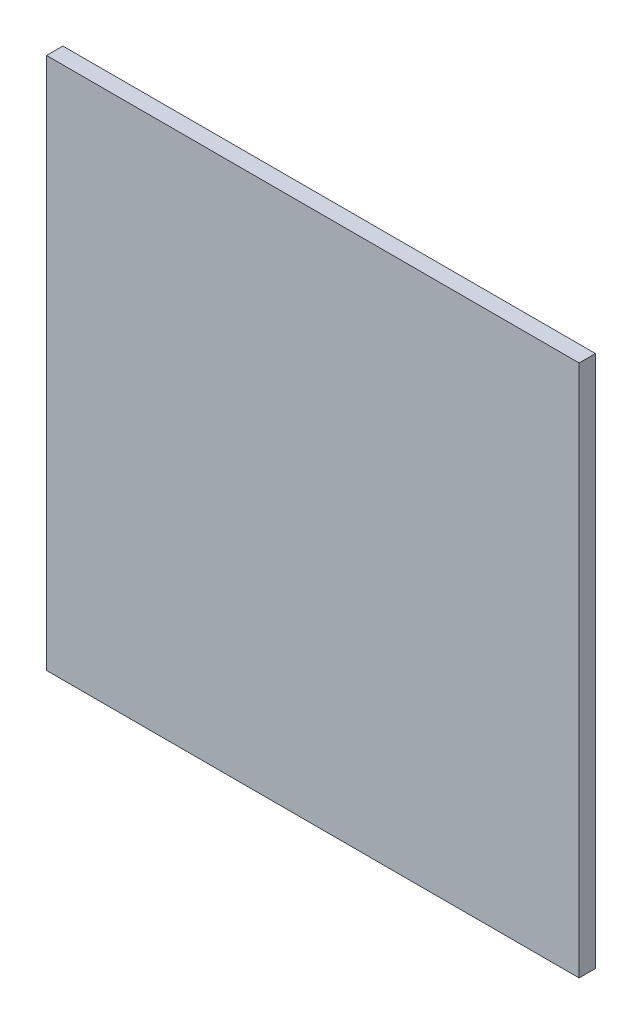
from build123d import *

# Parameters (mm, degrees)
SKETCH_1_W      = 75
SKETCH_1_H      = 75
EXTRUDE_1_DEPTH = 2.3


with BuildPart() as part:
    # 草图1 → 凸台-拉伸1 (new body)
    with BuildSketch(Plane.XY):
        with Locations((303.743807328, 184.689725504)):
            Rectangle(SKETCH_1_W, SKETCH_1_H)
    extrude(amount=EXTRUDE_1_DEPTH)


solid = part.part
